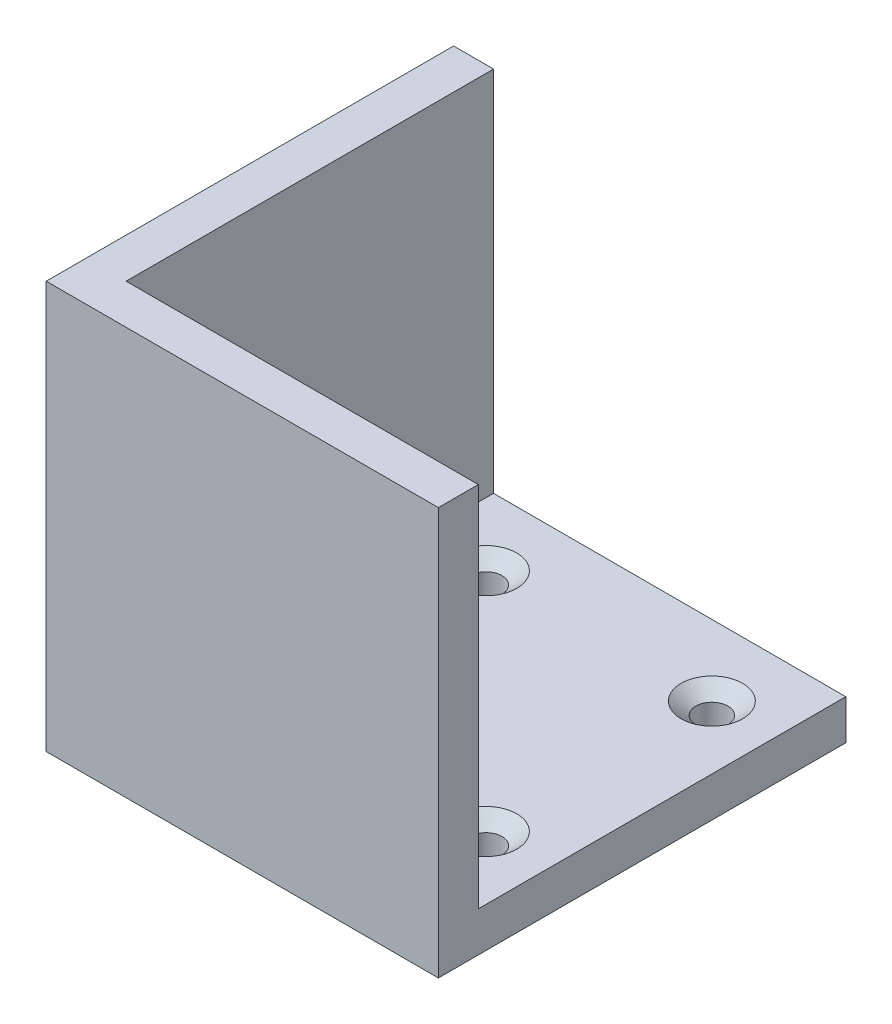
from build123d import *

# Parameters (mm, degrees)
MOTORPROFILE_W                                     = 56
MOTORPROFILE_H                                     = 58.42
BOSS_EXTRUDE2_DEPTH                                = 6.35
BOSS_EXTRUDE3_DEPTH                                = 64.77
CSK_FOR_10_FLAT_HEAD_MACHINE_SCREW_100_D           = 5.1054
CSK_FOR_10_FLAT_HEAD_MACHINE_SCREW_100_CSINK_D     = 9.779
CSK_FOR_10_FLAT_HEAD_MACHINE_SCREW_100_CSINK_ANGLE = 100


with BuildPart() as part:
    # MotorProfile → Boss-Extrude2 (new body)
    with BuildSketch(Plane(origin=(0, 0, 0), x_dir=(1, 0, 0), z_dir=(0, 1, 0))):
        Rectangle(MOTORPROFILE_W, MOTORPROFILE_H)
    extrude(amount=BOSS_EXTRUDE2_DEPTH)

    # Sketch2 → Boss-Extrude3 (add)
    with BuildSketch(Plane(origin=(0, 0, 0), x_dir=(1, 0, 0), z_dir=(0, 1, 0))):
        Polygon((-34.35, 29.21), (-34.35, -35.56), (28, -35.56), (28, -29.21), (-28, -29.21), (-28, 29.21), align=None)
    extrude(amount=BOSS_EXTRUDE3_DEPTH)

    # CSK for #10 Flat Head Machine Screw (100)1 (through all)
    with Locations(Plane(origin=(0, 6.35, 0), x_dir=(1, 0, 0), z_dir=(0, 1, 0))):
        with Locations((-17.960512242, 17.960512242), (-17.960512242, -17.960512242), (17.960512242, -17.960512242), (17.960512242, 17.960512242)):
            CounterSinkHole(CSK_FOR_10_FLAT_HEAD_MACHINE_SCREW_100_D / 2, CSK_FOR_10_FLAT_HEAD_MACHINE_SCREW_100_CSINK_D / 2, counter_sink_angle=CSK_FOR_10_FLAT_HEAD_MACHINE_SCREW_100_CSINK_ANGLE)


solid = part.part
